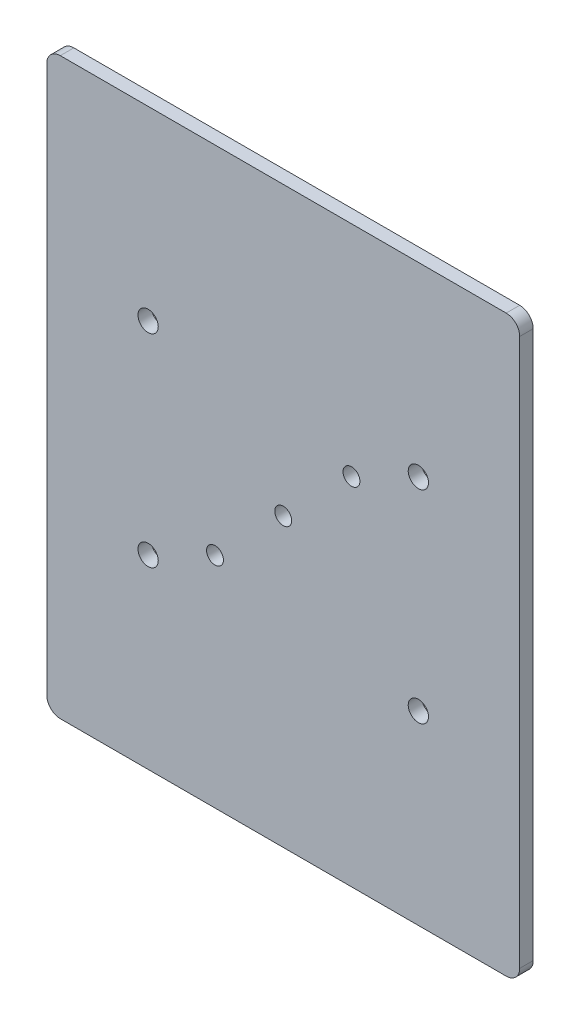
from build123d import *

# Parameters (mm, degrees)
SKETCH_1_W      = 70
SKETCH_1_H      = 85
SKETCH_1_R      = 1.5
SKETCH_1_R_2    = 1.25
EXTRUDE_1_DEPTH = 2
FILLET_1_R      = 2


with BuildPart() as part:
    # 草图1 → 凸台-拉伸1 (new body)
    with BuildSketch(Plane.XY):
        Rectangle(SKETCH_1_W, SKETCH_1_H)
        with Locations((-20, 15)):
            Circle(SKETCH_1_R, mode=Mode.SUBTRACT)
        with Locations((20, 15)):
            Circle(SKETCH_1_R, mode=Mode.SUBTRACT)
        with Locations((-20, -15)):
            Circle(SKETCH_1_R, mode=Mode.SUBTRACT)
        with Locations((20, -15)):
            Circle(SKETCH_1_R, mode=Mode.SUBTRACT)
        with Locations((10.1, 10.1)):
            Circle(SKETCH_1_R_2, mode=Mode.SUBTRACT)
        with Locations((-10.1, -10.1)):
            Circle(SKETCH_1_R_2, mode=Mode.SUBTRACT)
        Circle(SKETCH_1_R_2, mode=Mode.SUBTRACT)
    extrude(amount=EXTRUDE_1_DEPTH)

    # 圆角1
    fillet_1_edges = [part.edges().sort_by_distance(p)[0] for p in [
        (35, -42.5, 1),
        (-35, -42.5, 1),
        (-35, 42.5, 1),
        (35, 42.5, 1),
    ]]
    fillet(fillet_1_edges, radius=FILLET_1_R)


solid = part.part
